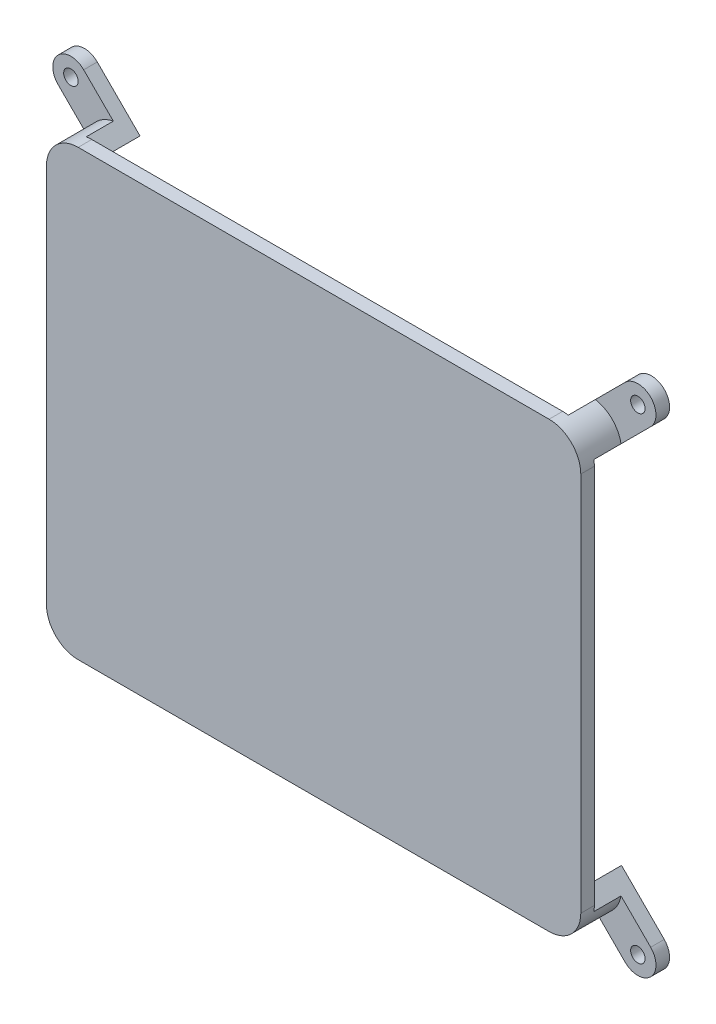
from build123d import *

# Parameters (mm, degrees)
BOSS_EXTRUDE1_DEPTH     = 3
BOSS_EXTRUDE2_DEPTH     = 6
SKETCH3_R               = 1.6
BOSS_EXTRUDE3_DEPTH     = 3
MIRROR2_COPY_1_DEPTH    = 6
MIRROR2_COPY_2_SKETCH_R = 1.6
MIRROR2_COPY_2_DEPTH    = 3


with BuildPart() as part:
    # Sketch1 → Boss-Extrude1 (new body)
    with BuildSketch(Plane.XY):
        with BuildLine():
            Line((-71.122052126, 155), (-71.122052126, 71))
            ThreePointArc((-71.122052126, 71), (-69.071799594, 66.050252532), (-64.122052126, 64))
            Line((-64.122052126, 64), (39.877947874, 64))
            ThreePointArc((39.877947874, 64), (44.827695342, 66.050252532), (46.877947874, 71))
            Line((46.877947874, 71), (46.877947874, 155))
            ThreePointArc((46.877947874, 155), (44.827695342, 159.949747468), (39.877947874, 162))
            Line((39.877947874, 162), (-64.122052126, 162))
            ThreePointArc((-64.122052126, 162), (-69.071799594, 159.949747468), (-71.122052126, 155))
        make_face()
    extrude(amount=-BOSS_EXTRUDE1_DEPTH)

    # Sketch2 → Boss-Extrude2 (add)
    with BuildSketch(Plane(origin=(0, 0, -3), x_dir=(-1, 0, 0), z_dir=(0, 0, -1))):
        with BuildLine():
            Line((-46.768394201, 156.233592078), (-43.877947874, 153.343145751))
            Line((-43.877947874, 153.343145751), (-43.877947874, 155))
            ThreePointArc((-43.877947874, 155), (-42.706374999, 157.828427125), (-39.877947874, 159))
            Line((-39.877947874, 159), (-38.221093625, 159))
            Line((-38.221093625, 159), (-41.111539952, 161.890446327))
            ThreePointArc((-41.111539952, 161.890446327), (-44.827695342, 159.949747468), (-46.768394201, 156.233592078))
        make_face()
    boss_extrude2 = extrude(amount=BOSS_EXTRUDE2_DEPTH)

    # Sketch3 → Boss-Extrude3 (add)
    with BuildSketch(Plane(origin=(0, 0, -9), x_dir=(-1, 0, 0), z_dir=(0, 0, -1))):
        with BuildLine():
            Line((-43.877947874, 153.343145751), (-43.877947874, 155))
            ThreePointArc((-43.877947874, 155), (-42.706374999, 157.828427125), (-39.877947874, 159))
            Line((-39.877947874, 159), (-38.221093625, 159))
            Line((-38.221093625, 159), (-47.656122467, 168.435028843))
            ThreePointArc((-47.656122467, 168.435028843), (-53.312976717, 168.435028843), (-53.312976717, 162.778174593))
            Line((-53.312976717, 162.778174593), (-43.877947874, 153.343145751))
        make_face()
        with Locations((-50.484549592, 165.606601718)):
            Circle(SKETCH3_R, mode=Mode.SUBTRACT)
    boss_extrude3 = extrude(amount=BOSS_EXTRUDE3_DEPTH)

    # Mirror1: Boss-Extrude2, Boss-Extrude3 across plane
    add(boss_extrude2.mirror(Plane.ZY.offset(12.122052126)))
    add(boss_extrude3.mirror(Plane.ZY.offset(12.122052126)))

    # Mirror2: Boss-Extrude2, Boss-Extrude3 across plane
    add(boss_extrude2.mirror(Plane.ZX.offset(113)))
    add(boss_extrude3.mirror(Plane.ZX.offset(113)))

    # Mirror2 copy 1 sketch → Mirror2 copy 1 (add)
    with BuildSketch(Plane(origin=(-24.244104252, 226, -3), x_dir=(1, 0, 0), z_dir=(0, 0, -1))):
        with BuildLine():
            Line((-46.768394201, 156.233592078), (-43.877947874, 153.343145751))
            Line((-43.877947874, 153.343145751), (-43.877947874, 155))
            ThreePointArc((-43.877947874, 155), (-42.706374999, 157.828427125), (-39.877947874, 159))
            Line((-39.877947874, 159), (-38.221093625, 159))
            Line((-38.221093625, 159), (-41.111539952, 161.890446327))
            ThreePointArc((-41.111539952, 161.890446327), (-44.827695342, 159.949747468), (-46.768394201, 156.233592078))
        make_face()
    extrude(amount=MIRROR2_COPY_1_DEPTH)

    # Mirror2 copy 2 sketch → Mirror2 copy 2 (add)
    with BuildSketch(Plane(origin=(-24.244104252, 226, -9), x_dir=(1, 0, 0), z_dir=(0, 0, -1))):
        with BuildLine():
            Line((-43.877947874, 153.343145751), (-43.877947874, 155))
            ThreePointArc((-43.877947874, 155), (-42.706374999, 157.828427125), (-39.877947874, 159))
            Line((-39.877947874, 159), (-38.221093625, 159))
            Line((-38.221093625, 159), (-47.656122467, 168.435028843))
            ThreePointArc((-47.656122467, 168.435028843), (-53.312976717, 168.435028843), (-53.312976717, 162.778174593))
            Line((-53.312976717, 162.778174593), (-43.877947874, 153.343145751))
        make_face()
        with Locations((-50.484549592, 165.606601718)):
            Circle(MIRROR2_COPY_2_SKETCH_R, mode=Mode.SUBTRACT)
    extrude(amount=MIRROR2_COPY_2_DEPTH)


solid = part.part
